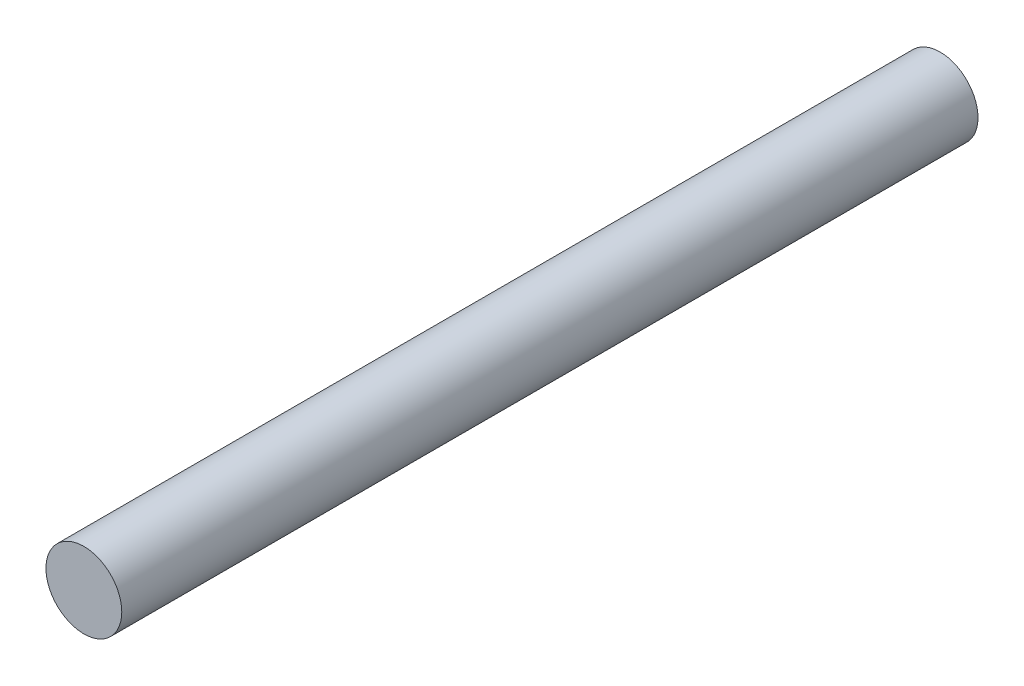
from build123d import *

# Parameters (mm, degrees)
SKETCH1_R           = 10
BOSS_EXTRUDE1_DEPTH = 112.900235935


with BuildPart() as part:
    # Sketch1 → Boss-Extrude1 (new body, symmetric)
    with BuildSketch(Plane.XY):
        with Locations((-11.012505787, 8.017814855)):
            Circle(SKETCH1_R)
    extrude(amount=BOSS_EXTRUDE1_DEPTH, both=True)


solid = part.part
